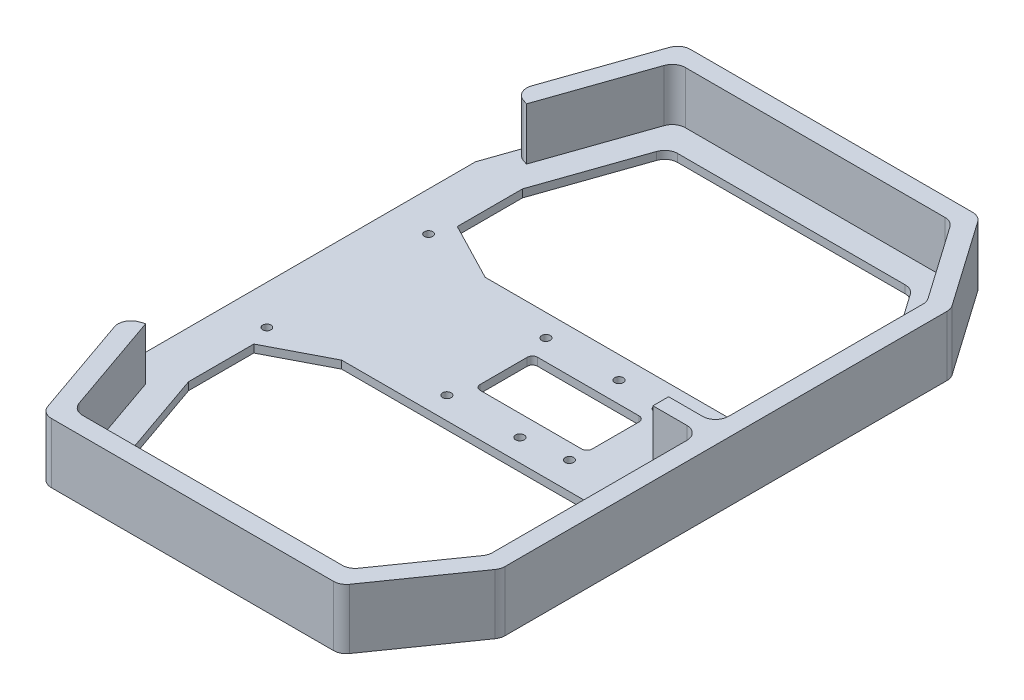
from build123d import *

# Parameters (mm, degrees)
SKETCH1_R           = 1.5999999999999992
SKETCH1_R_2         = 1.6
BOSS_EXTRUDE1_DEPTH = 1.5
BOSS_EXTRUDE2_DEPTH = 20
FILLET1_R           = 5
SKETCH2_R           = 1.6500000000000017
SKETCH2_W           = 42.900000000000006
SKETCH2_H           = 21.999999999999993
CUT_EXTRUDE1_DEPTH  = 191.86971996626394
FILLET2_R           = 2


with BuildPart() as part:
    # Sketch1 → Boss-Extrude1 (new, symmetric)
    with BuildSketch(Plane(origin=(0, 0, 0), x_dir=(1, 0, 0), z_dir=(0, 1, 0))):
        Polygon((-15, -39), (-15, 39), (-14.999999999999993, 64), (5.358274547724965, 122.5), (119.64234676884817, 122.50000000000003), (145.00000000000003, 86.28551808227317), (145.00000000000003, -86.28551808227317), (119.64234676884817, -122.50000000000003), (5.358274547725049, -122.49999999999999), (-14.999999999999993, -64), align=None)
        with Locations(Location((0, 31, 0), (0, 0, 270))):
            Circle(SKETCH1_R, mode=Mode.SUBTRACT)
        with Locations(Location((0, -31, 0), (0, 0, 90))):
            Circle(SKETCH1_R_2, mode=Mode.SUBTRACT)
        Polygon((25.197972880423116, 27.499999999999996), (128, 27.499999999999996), (128, 80.92543867133034), (110.7927069094685, 105.50000000000004), (17.442194764625423, 105.50000000000001), (3.0000000000000027, 64), (3.0000000000000027, 39), align=None, mode=Mode.SUBTRACT)
        Polygon((25.197972880423116, -27.499999999999996), (128, -27.499999999999996), (128, -80.92543867133034), (110.7927069094685, -105.50000000000004), (17.442194764625537, -105.49999999999999), (3.0000000000000027, -64), (3.0000000000000027, -39), align=None, mode=Mode.SUBTRACT)
    extrude(amount=BOSS_EXTRUDE1_DEPTH, both=True)

    # Sketch3 → Boss-Extrude2 (add)
    with BuildSketch(Plane(origin=(0, 1.5, 0), x_dir=(1, 0, 0), z_dir=(0, 1, 0))):
        Polygon((120.00000000000004, -2.999999999999993), (120.00000000000004, 3.0000000000000075), (138, 3.0000000000000075), (138, 84.07842656012029), (115.99837741498601, 115.49999999999999), (10.334006401742785, 115.49999999999997), (-4.464169294218266, 72.97708008435012), (-11.07528040532939, 75.27777777777771), (5.358274547724965, 122.5), (119.64234676884817, 122.50000000000003), (145.00000000000003, 86.28551808227317), (145.00000000000003, -86.28551808227317), (119.64234676884817, -122.50000000000003), (5.358274547724965, -122.5), (-11.075280405329384, -75.27777777777771), (-4.464169294218257, -72.97708008435012), (10.334006401742798, -115.49999999999997), (115.99837741498602, -115.49999999999996), (138, -84.07842656012026), (138, -2.999999999999991), align=None)
    extrude(amount=BOSS_EXTRUDE2_DEPTH)

    # Fillet1
    fillet1_edges = [part.edges().sort_by_distance(p)[0] for p in [
        (115.99837741498602, 11.5, 115.49999999999996),
        (10.334006401742798, 11.5, 115.49999999999997),
        (-11.075280405329384, 11.5, 75.27777777777771),
        (-11.07528040532939, 11.5, -75.27777777777771),
        (10.334006401742785, 11.5, -115.49999999999997),
        (115.99837741498601, 11.5, -115.49999999999999),
        (138, 11.5, -84.07842656012029),
        (5.358274547724965, 10, -122.5),
        (119.64234676884817, 10, -122.50000000000003),
        (145.00000000000003, 10, -86.28551808227317),
        (145.00000000000003, 10, 86.28551808227317),
        (119.64234676884817, 10, 122.50000000000003),
        (5.358274547725006, 10, 122.5),
        (128, 0, -80.92543867133034),
        (110.7927069094685, 0, -105.50000000000004),
        (17.442194764625423, 0, -105.50000000000001),
        (138, 11.5, -3.0000000000000075),
        (138, 11.5, 2.999999999999991),
        (138, 11.5, 84.07842656012026),
    ]]
    fillet(fillet1_edges, radius=FILLET1_R)

    # Sketch2 → Cut-Extrude1 (cut, through all)
    with BuildSketch(Plane(origin=(0, 1.5, 0), x_dir=(1, 0, 0), z_dir=(0, 1, 0))):
        with Locations(Location((56.999999999999964, 18.99999999999999, 0), (0, 0, 270))):
            Circle(SKETCH2_R)
        with Locations(Location((84.99999999999997, 18.999999999999993, 0), (0, 0, 270))):
            Circle(SKETCH2_R)
        with Locations(Location((101.99999999999999, 16.999999999999996, 0), (0, 0, 270))):
            Circle(SKETCH2_R)
        with Locations(Location((101.99999999999999, -16.999999999999996, 0), (0, 0, 90))):
            Circle(SKETCH2_R)
        with Locations(Location((84.99999999999997, -18.999999999999993, 0), (0, 0, 90))):
            Circle(SKETCH2_R)
        with Locations(Location((56.999999999999964, -18.99999999999999, 0), (0, 0, 90))):
            Circle(SKETCH2_R)
        with Locations((81.24999999999999, 3.819e-14)):
            Rectangle(SKETCH2_W, SKETCH2_H)
    extrude(amount=-CUT_EXTRUDE1_DEPTH, mode=Mode.SUBTRACT)

    # Fillet2
    fillet2_edges = [part.edges().sort_by_distance(p)[0] for p in [
        (59.79999999999998, 0, -11.000000000000036),
        (102.69999999999999, 0, -11.000000000000036),
        (102.69999999999999, 0, 10.99999999999996),
        (59.79999999999998, 0, 10.99999999999996),
    ]]
    fillet(fillet2_edges, radius=FILLET2_R)


solid = part.part
